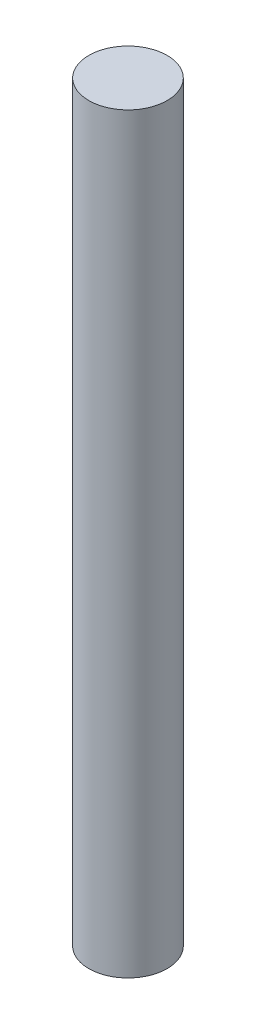
from build123d import *

# Parameters (mm, degrees)
SKETCH1_R           = 3.96875
BOSS_EXTRUDE1_DEPTH = 76.2


with BuildPart() as part:
    # Sketch1 → Boss-Extrude1 (new body)
    with BuildSketch(Plane(origin=(0, 0, 0), x_dir=(1, 0, 0), z_dir=(0, 1, 0))):
        Circle(SKETCH1_R)
    extrude(amount=BOSS_EXTRUDE1_DEPTH)


solid = part.part
